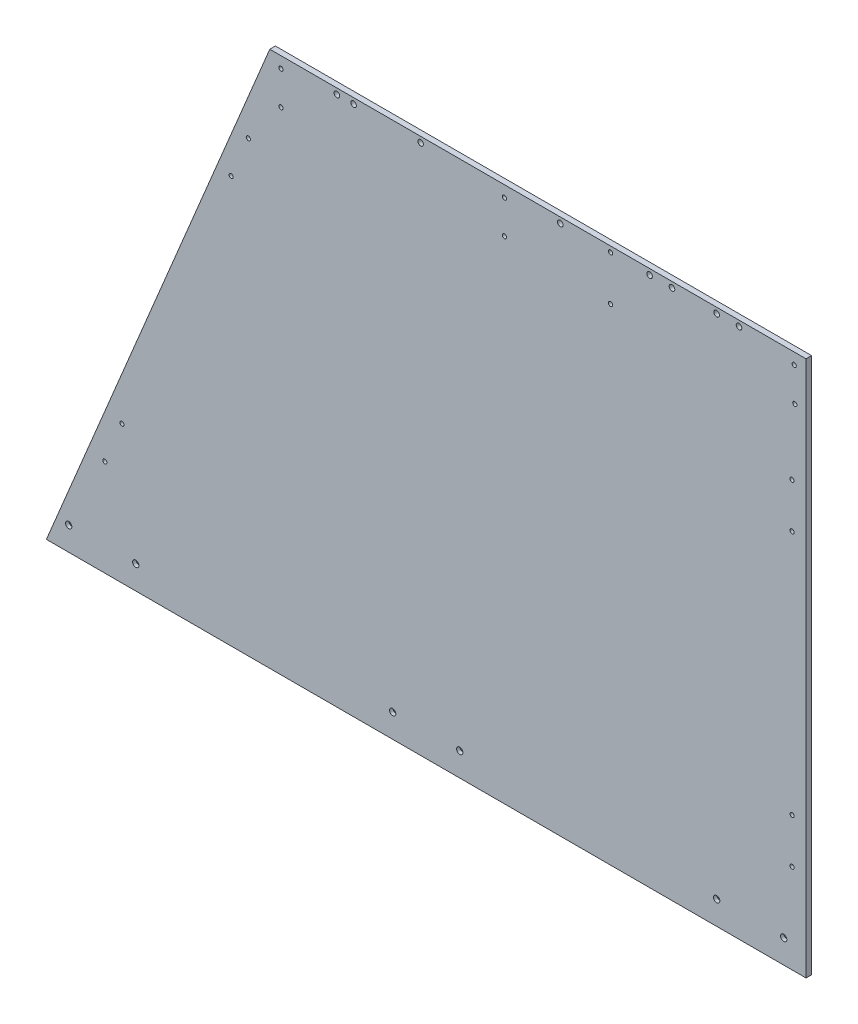
from build123d import *

# Parameters (mm, degrees)
BOSS_EXTRUDE1_DEPTH                                 = 6.35
SKETCH2_R                                           = 2.413
SKETCH2_R_2                                         = 2.38125
SKETCH2_R_3                                         = 3.175
SKETCH2_R_4                                         = 3.132970175
CUT_EXTRUDE1_DEPTH                                  = 7.35
SKETCH3_R                                           = 3.175
CUT_EXTRUDE2_DEPTH                                  = 6.35
SKETCH4_R                                           = 3.175
SKETCH4_R_2                                         = 2.413
CUT_EXTRUDE3_DEPTH                                  = 6.35
CSK_FOR_1_4_FLAT_HEAD_MACHINE_SCREW_100_D           = 7.14248
CSK_FOR_1_4_FLAT_HEAD_MACHINE_SCREW_100_CSINK_D     = 12.8778
CSK_FOR_1_4_FLAT_HEAD_MACHINE_SCREW_100_CSINK_ANGLE = 100


with BuildPart() as part:
    # Sketch1 → Boss-Extrude1 (new body)
    with BuildSketch(Plane.XY):
        Polygon((0, 0), (0, -609.6), (-863.6, -609.6), (-609.6, 0), align=None)
    extrude(amount=-BOSS_EXTRUDE1_DEPTH)

    # Sketch2 → Cut-Extrude1 (cut, through all)
    with BuildSketch(Plane(origin=(0, 0, -6.35), x_dir=(-1, 0, 0), z_dir=(0, 0, -1))):
        with Locations((342.899999998, -50.8)):
            Circle(SKETCH2_R)
        with Locations((342.899999998, -12.7)):
            Circle(SKETCH2_R)
        with Locations((596.9, -12.7)):
            Circle(SKETCH2_R)
        with Locations((596.9, -50.8)):
            Circle(SKETCH2_R)
        with Locations((13.462, -12.7)):
            Circle(SKETCH2_R)
        with Locations((12.699999998, -50.8)):
            Circle(SKETCH2_R)
        with Locations((15.875, -127.021365893)):
            Circle(SKETCH2_R_2)
        with Locations((15.875, -177.821365893)):
            Circle(SKETCH2_R_2)
        with Locations((15.875, -457.102337624)):
            Circle(SKETCH2_R_2)
        with Locations((15.875, -507.902337624)):
            Circle(SKETCH2_R_2)
        with Locations((101.6, -582.717913572)):
            Circle(SKETCH2_R_3)
        with Locations((25.4, -582.717913572)):
            Circle(SKETCH2_R_3)
        with Locations((762, -582.717913572)):
            Circle(SKETCH2_R_3)
        with Locations((838.2, -582.717913572)):
            Circle(SKETCH2_R_3)
        with Locations((797.119710917, -499.5773062)):
            Circle(SKETCH2_R_2)
        with Locations((777.581249378, -452.684998508)):
            Circle(SKETCH2_R_2)
        with Locations((653.56789881, -146.797957145)):
            Circle(SKETCH2_R_2)
        with Locations((634.023076923, -99.890384615)):
            Circle(SKETCH2_R_2)
        with Locations((514.35, -6.35)):
            Circle(SKETCH2_R_4)
        with Locations((438.15, -6.35)):
            Circle(SKETCH2_R_4)
        with Locations((469.9, -582.717913572)):
            Circle(SKETCH2_R_3)
        with Locations((393.7, -582.717913572)):
            Circle(SKETCH2_R_3)
    extrude(amount=-CUT_EXTRUDE1_DEPTH, mode=Mode.SUBTRACT)

    # Sketch3 → Cut-Extrude2 (cut)
    with BuildSketch(Plane.XY):
        with Locations((-177.8, -6.35)):
            Circle(SKETCH3_R)
        with Locations((-152.4, -6.35)):
            Circle(SKETCH3_R)
        with Locations((-101.6, -6.35)):
            Circle(SKETCH3_R)
        with Locations((-76.2, -6.35)):
            Circle(SKETCH3_R)
    extrude(amount=-CUT_EXTRUDE2_DEPTH, mode=Mode.SUBTRACT)

    # Sketch4 → Cut-Extrude3 (cut)
    with BuildSketch(Plane(origin=(0, 0, -6.35), x_dir=(-1, 0, 0), z_dir=(0, 0, -1))):
        with Locations((533.4, -6.35)):
            Circle(SKETCH4_R)
        with Locations((279.4, -6.35)):
            Circle(SKETCH4_R)
        with Locations((222.25, -6.35)):
            Circle(SKETCH4_R_2)
        with Locations((222.25, -57.15)):
            Circle(SKETCH4_R_2)
    extrude(amount=-CUT_EXTRUDE3_DEPTH, mode=Mode.SUBTRACT)

    # CSK for 1/4 Flat Head Machine Screw (100)1 (through all)
    with Locations(Plane(origin=(-25.4, -582.717913572, -6.35), x_dir=(-1, 0, 0), z_dir=(0, 0, -1))):
        with Locations((0, 0), (76.2, 0), (368.3, 0), (444.5, 0), (736.6, 0), (812.8, 0)):
            CounterSinkHole(CSK_FOR_1_4_FLAT_HEAD_MACHINE_SCREW_100_D / 2, CSK_FOR_1_4_FLAT_HEAD_MACHINE_SCREW_100_CSINK_D / 2, counter_sink_angle=CSK_FOR_1_4_FLAT_HEAD_MACHINE_SCREW_100_CSINK_ANGLE)


solid = part.part
